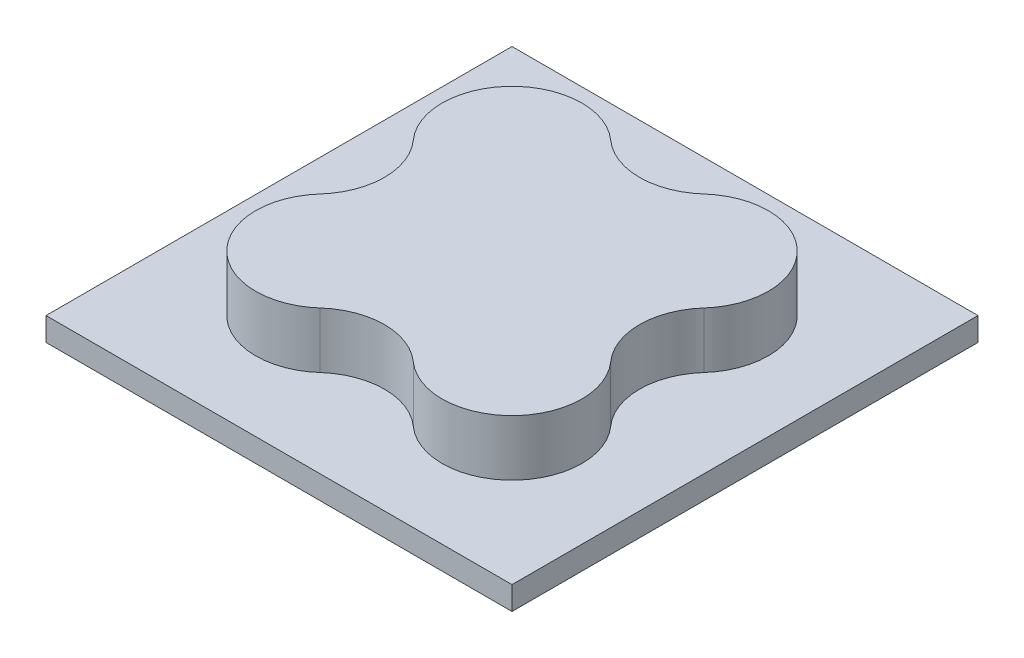
from build123d import *

# Parameters (mm, degrees)
SKETCH5_W           = 100
SKETCH5_H           = 100
BOSS_EXTRUDE1_DEPTH = 5
BOSS_EXTRUDE2_DEPTH = 12


with BuildPart() as part:
    # Sketch5 → Boss-Extrude1 (new body)
    with BuildSketch(Plane(origin=(0, 0, 0), x_dir=(1, 0, 0), z_dir=(0, 1, 0))):
        with Locations((50, 50)):
            Rectangle(SKETCH5_W, SKETCH5_H)
    extrude(amount=BOSS_EXTRUDE1_DEPTH)

    # Sketch7 → Boss-Extrude2 (add)
    with BuildSketch(Plane(origin=(0, 5, 0), x_dir=(1, 0, 0), z_dir=(0, 1, 0))):
        with BuildLine():
            ThreePointArc((81.180339887, 60), (80.606601718, 80.606601718), (60, 81.180339887))
            ThreePointArc((60, 81.180339887), (50, 77.360679775), (40, 81.180339887))
            ThreePointArc((40, 81.180339887), (19.393398282, 80.606601718), (18.819660113, 60))
            ThreePointArc((18.819660113, 60), (22.639320225, 50), (18.819660113, 40))
            ThreePointArc((18.819660113, 40), (19.393398282, 19.393398282), (40, 18.819660113))
            ThreePointArc((40, 18.819660113), (50, 22.639320225), (60, 18.819660113))
            ThreePointArc((60, 18.819660113), (80.606601718, 19.393398282), (81.180339887, 40))
            ThreePointArc((81.180339887, 40), (77.360679775, 50), (81.180339887, 60))
        make_face()
    extrude(amount=BOSS_EXTRUDE2_DEPTH)


solid = part.part
